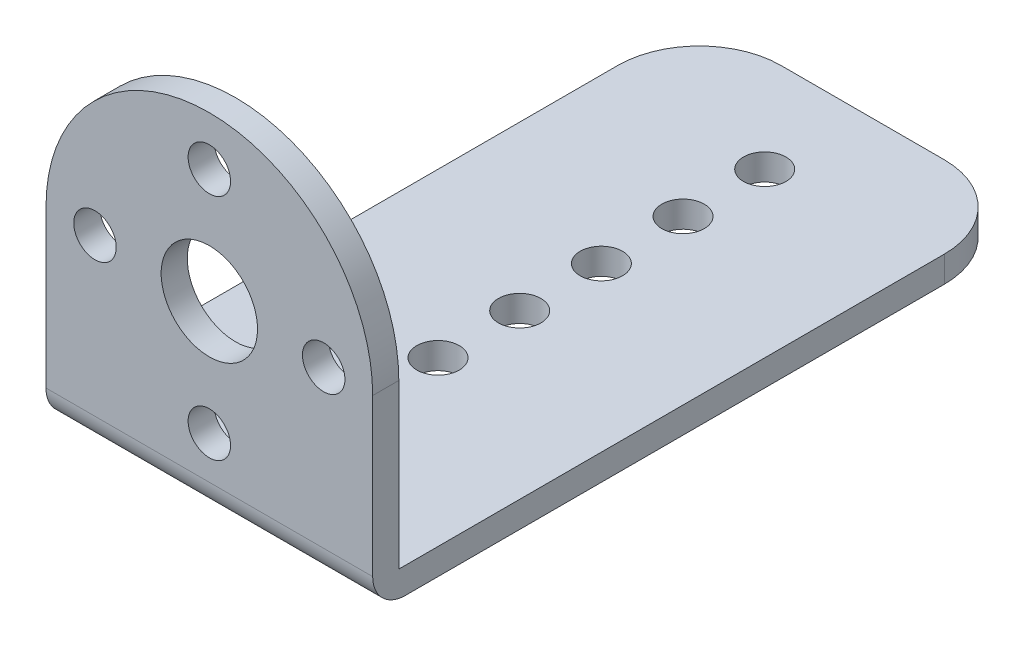
from build123d import *

# Parameters (mm, degrees)
SKETCH1_R           = 3.7465
SKETCH1_R_2         = 1.651
BOSS_EXTRUDE1_DEPTH = 2.032
SKETCH2_W           = 25.4
SKETCH2_H           = 50.8
SKETCH2_R           = 1.651
BOSS_EXTRUDE3_DEPTH = 2.032
FILLET3_R           = 2.54
FILLET4_R           = 6.35


with BuildPart() as part:
    # Sketch1 → Boss-Extrude1 (new body)
    with BuildSketch(Plane.XY):
        with BuildLine():
            Line((-12.7, 0), (-12.7, -14.732))
            Line((-12.7, -14.732), (12.7, -14.732))
            Line((12.7, -14.732), (12.7, 0))
            ThreePointArc((12.7, 0), (0, 12.7), (-12.7, 0))
        make_face()
        Circle(SKETCH1_R, mode=Mode.SUBTRACT)
        with Locations((0, 8.89)):
            Circle(SKETCH1_R_2, mode=Mode.SUBTRACT)
        with Locations((8.89, 0)):
            Circle(SKETCH1_R_2, mode=Mode.SUBTRACT)
        with Locations((0, -8.89)):
            Circle(SKETCH1_R_2, mode=Mode.SUBTRACT)
        with Locations((-8.89, 0)):
            Circle(SKETCH1_R_2, mode=Mode.SUBTRACT)
    extrude(amount=-BOSS_EXTRUDE1_DEPTH)

    # Sketch2 → Boss-Extrude3 (add)
    with BuildSketch(Plane.XZ.offset(14.732)):
        with Locations((0, -25.4)):
            Rectangle(SKETCH2_W, SKETCH2_H)
        with Locations((0, -43.18)):
            Circle(SKETCH2_R, mode=Mode.SUBTRACT)
        with Locations((0, -36.83)):
            Circle(SKETCH2_R, mode=Mode.SUBTRACT)
        with Locations((0, -30.48)):
            Circle(SKETCH2_R, mode=Mode.SUBTRACT)
        with Locations((0, -24.13)):
            Circle(SKETCH2_R, mode=Mode.SUBTRACT)
        with Locations((0, -17.78)):
            Circle(SKETCH2_R, mode=Mode.SUBTRACT)
        with Locations((0, -11.43)):
            Circle(SKETCH2_R, mode=Mode.SUBTRACT)
        with Locations((0, -5.08)):
            Circle(SKETCH2_R, mode=Mode.SUBTRACT)
    extrude(amount=-BOSS_EXTRUDE3_DEPTH)

    # Fillet3
    fillet3_edges = [part.edges().sort_by_distance(p)[0] for p in [
        (0, -14.732, 0),
    ]]
    fillet(fillet3_edges, radius=FILLET3_R)

    # Fillet4
    fillet4_edges = [part.edges().sort_by_distance(p)[0] for p in [
        (-12.7, -13.716, -50.8),
        (12.7, -13.716, -50.8),
    ]]
    fillet(fillet4_edges, radius=FILLET4_R)


solid = part.part
